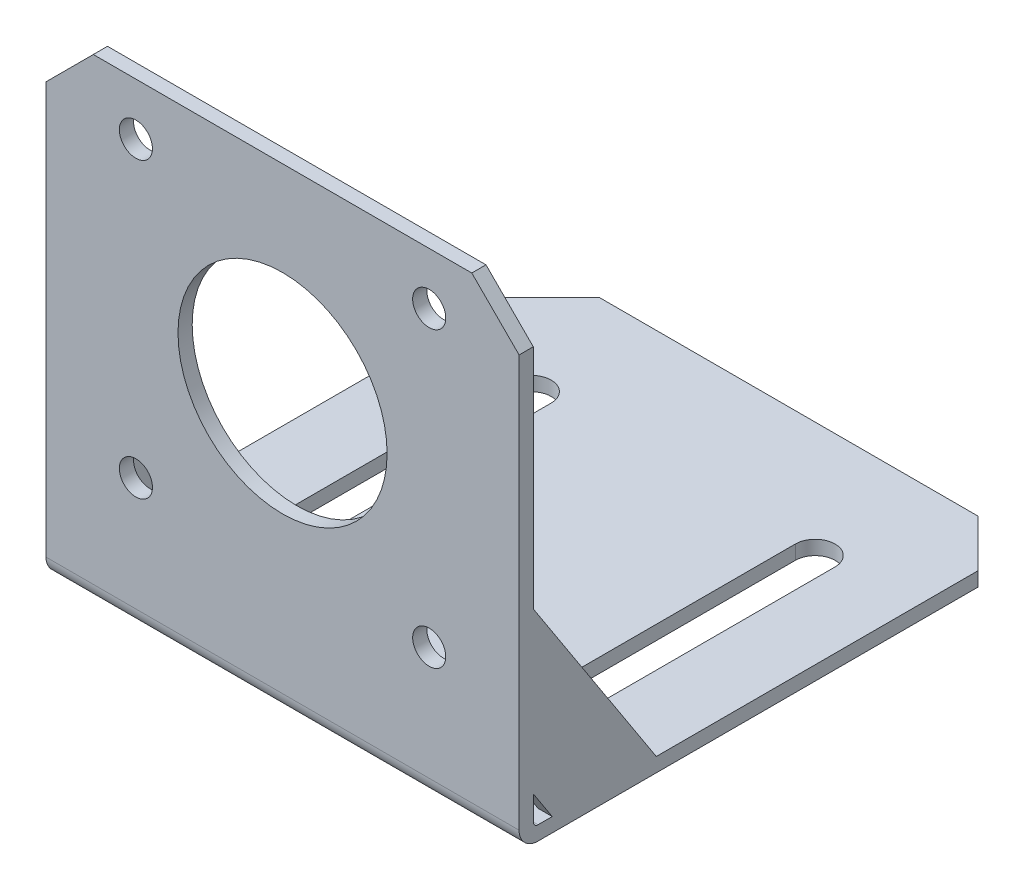
from build123d import *

# Parameters (mm, degrees)
LINEAR_AUSTRAGEN_D_NN1_DEPTH    = 50
SKIZZE2_R                       = 11.05
SKIZZE2_R_2                     = 1.75
SCHNITT_LINEAR_AUSTRAGEN1_DEPTH = 2.5
AUFSATZ_LINEAR_AUSTRAGEN1_DEPTH = 1.5
SCHNITT_LINEAR_AUSTRAGEN2_DEPTH = 2.5
FASE1_SIZE                      = 5


with BuildPart() as part:
    # Skizze1 → Linear-Austragen-Dünn1 (new body)
    with BuildSketch(Plane(origin=(0, 0, 0), x_dir=(0, 0, -1), z_dir=(1, 0, 0))):
        with BuildLine():
            Line((53.5, 0), (2, 0))
            ThreePointArc((2, 0), (0.585786438, 0.585786438), (0, 2))
            Line((0, 2), (0, 50.5))
            Line((0, 50.5), (1.5, 50.5))
            Line((1.5, 50.5), (1.5, 2))
            ThreePointArc((1.5, 2), (1.646446609, 1.646446609), (2, 1.5))
            Line((2, 1.5), (53.5, 1.5))
            Line((53.5, 1.5), (53.5, 0))
        make_face()
    extrude(amount=LINEAR_AUSTRAGEN_D_NN1_DEPTH)

    # Skizze2 → Schnitt-Linear austragen1 (cut, through all)
    with BuildSketch(Plane(origin=(0, 0, -1.5), x_dir=(-1, 0, 0), z_dir=(0, 0, -1))):
        with Locations((-25, 29.5)):
            Circle(SKIZZE2_R)
        with Locations((-40.5, 45)):
            Circle(SKIZZE2_R_2)
        with Locations((-9.5, 45)):
            Circle(SKIZZE2_R_2)
        with Locations((-9.5, 14)):
            Circle(SKIZZE2_R_2)
        with Locations((-40.5, 14)):
            Circle(SKIZZE2_R_2)
    extrude(amount=-SCHNITT_LINEAR_AUSTRAGEN1_DEPTH, mode=Mode.SUBTRACT)

    # Skizze3 → Aufsatz-Linear austragen1 (add)
    with BuildSketch(Plane(origin=(50, 0, 0), x_dir=(0, 0, -1), z_dir=(1, 0, 0))):
        Polygon((1.5, 21.5), (14.5, 1.5), (3.5, 1.5), (1.5, 4.576923077), align=None)
    aufsatz_linear_austragen1 = extrude(amount=-AUFSATZ_LINEAR_AUSTRAGEN1_DEPTH)

    # Spiegeln1: Aufsatz-Linear austragen1 across plane
    add(aufsatz_linear_austragen1.mirror(Plane(origin=(25, 0, 0), x_dir=(0, 0, 1), z_dir=(1, 0, 0))))

    # Skizze4 → Schnitt-Linear austragen2 (cut, through all)
    with BuildSketch(Plane(origin=(0, 1.5, 0), x_dir=(1, 0, 0), z_dir=(0, 1, 0))):
        with BuildLine():
            Line((7.9, 13.706666488), (7.9, 41.293333512))
            ThreePointArc((7.9, 41.293333512), (10, 43.393333512), (12.1, 41.293333512))
            Line((12.1, 41.293333512), (12.1, 13.706666488))
            ThreePointArc((12.1, 13.706666488), (10, 11.606666488), (7.9, 13.706666488))
        make_face()
        with BuildLine():
            Line((42.1, 13.706666488), (42.1, 41.293333512))
            ThreePointArc((42.1, 41.293333512), (40, 43.393333512), (37.9, 41.293333512))
            Line((37.9, 41.293333512), (37.9, 13.706666488))
            ThreePointArc((37.9, 13.706666488), (40, 11.606666488), (42.1, 13.706666488))
        make_face()
    extrude(amount=-SCHNITT_LINEAR_AUSTRAGEN2_DEPTH, mode=Mode.SUBTRACT)

    # Fase1
    fase1_edges = [part.edges().sort_by_distance(p)[0] for p in [
        (50, 50.5, -0.75),
        (50, 0.75, -53.5),
        (0, 50.5, -0.75),
        (0, 0.75, -53.5),
    ]]
    chamfer(fase1_edges, length=FASE1_SIZE)


solid = part.part
